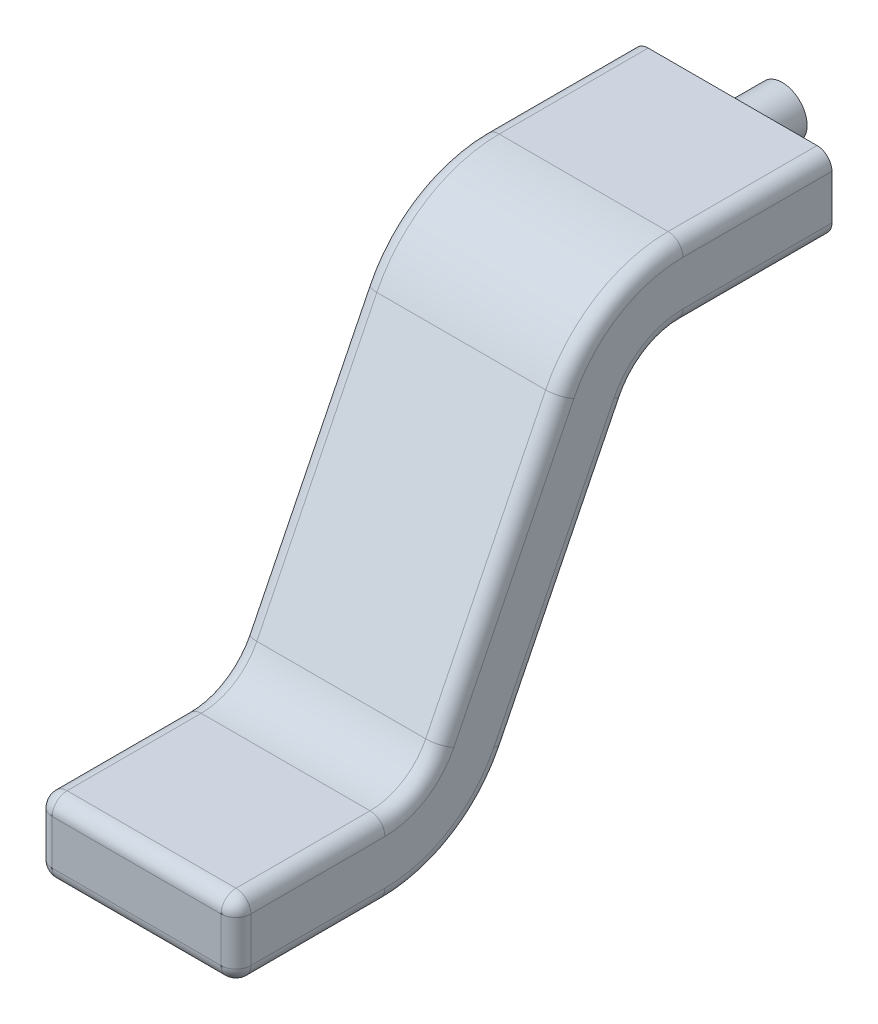
from build123d import *

# Parameters (mm, degrees)
FILETE2_R                = 0.03
ESBO_O3_R                = 0.05
RESSALTO_EXTRUS_O1_DEPTH = 0.1


with BuildPart() as part:
    # Varredura1: sweep along a path in Esboço2
    with BuildLine(Plane(origin=(0, 0, 0), x_dir=(0, 0, -1), z_dir=(1, 0, 0))) as varredura1_path:
        Line((0, 0), (0.3, 0))
        ThreePointArc((0.3, 0), (0.405455147, 0.030061152), (0.479209262, 0.11120788))
        Line((0.479209262, 0.11120788), (0.720790738, 0.59879212))
        ThreePointArc((0.720790738, 0.59879212), (0.794544853, 0.679938848), (0.9, 0.71))
        Line((0.9, 0.71), (1.2, 0.71))
    # Esboço1 → Varredura1 (sweep)
    with BuildSketch(Plane.XY):
        with BuildLine():
            Line((-0.17, -0.075), (0.17, -0.075))
            ThreePointArc((0.17, -0.075), (0.191213203, -0.066213203), (0.2, -0.045))
            Line((0.2, -0.045), (0.2, 0.045))
            ThreePointArc((0.2, 0.045), (0.191213203, 0.066213203), (0.17, 0.075))
            Line((0.17, 0.075), (-0.17, 0.075))
            ThreePointArc((-0.17, 0.075), (-0.191213203, 0.066213203), (-0.2, 0.045))
            Line((-0.2, 0.045), (-0.2, -0.045))
            ThreePointArc((-0.2, -0.045), (-0.191213203, -0.066213203), (-0.17, -0.075))
        make_face()
    sweep(path=varredura1_path.line)

    # Filete2
    filete2_edges = [part.edges().sort_by_distance(p)[0] for p in [
        (-0.2, 0, 0),
        (-0.191213203, 0.066213203, 0),
        (0, 0.075, 0),
        (0.191213203, 0.066213203, 0),
        (0.2, 0, 0),
        (0.191213203, -0.066213203, 0),
        (0, -0.075, 0),
        (-0.191213203, -0.066213203, 0),
    ]]
    fillet(filete2_edges, radius=FILETE2_R)

    # Esboço3 → Ressalto-extrusão1 (add)
    with BuildSketch(Plane(origin=(0, 0, -1.2), x_dir=(-1, 0, 0), z_dir=(0, 0, -1))):
        with Locations((0, 0.71)):
            Circle(ESBO_O3_R)
    extrude(amount=RESSALTO_EXTRUS_O1_DEPTH)


solid = part.part
